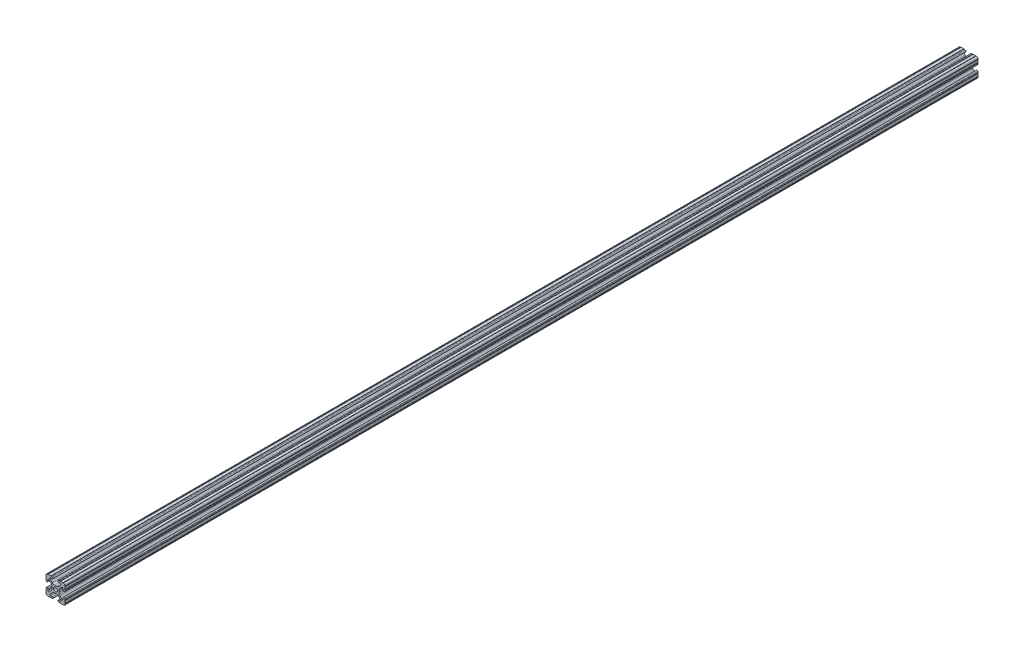
from build123d import *

# Parameters (mm, degrees)
SKETCH3_R      = 2.6035
EXTRUDE1_DEPTH = 609.6


with BuildPart() as part:
    # Sketch3 → Extrude1 (new body, symmetric)
    with BuildSketch(Plane.XY):
        with BuildLine():
            Line((-1.115277175, 4.5085), (1.115277175, 4.5085))
            ThreePointArc((1.115277175, 4.5085), (2.806584872, 4.844922018), (4.240406305, 5.80297087))
            Line((4.240406305, 5.80297087), (7.148423664, 8.710988229))
            ThreePointArc((7.148423664, 8.710988229), (7.349906316, 9.772227925), (6.436353897, 10.348636575))
            Line((6.436353897, 10.348636575), (4.381960454, 10.276895575))
            ThreePointArc((4.381960454, 10.276895575), (3.239173075, 11.342562046), (4.304839546, 12.485349424))
            Line((4.304839546, 12.485349424), (5.728246175, 12.535055879))
            ThreePointArc((5.728246175, 12.535055879), (6.054756855, 12.230579745), (6.35923299, 12.557090424))
            Line((6.35923299, 12.557090424), (9.782092278, 12.676619304))
            ThreePointArc((9.782092278, 12.676619304), (10.108602958, 12.37214317), (10.413079092, 12.69865385))
            ThreePointArc((10.413079092, 12.69865385), (12.052764565, 12.052764565), (12.69865385, 10.413079092))
            ThreePointArc((12.69865385, 10.413079092), (12.37214317, 10.108602958), (12.676619304, 9.782092278))
            Line((12.676619304, 9.782092278), (12.557090424, 6.35923299))
            ThreePointArc((12.557090424, 6.35923299), (12.230579745, 6.054756855), (12.535055879, 5.728246175))
            Line((12.535055879, 5.728246175), (12.485349424, 4.304839546))
            ThreePointArc((12.485349424, 4.304839546), (11.342562046, 3.239173075), (10.276895575, 4.381960454))
            Line((10.276895575, 4.381960454), (10.348636575, 6.436353897))
            ThreePointArc((10.348636575, 6.436353897), (9.772227925, 7.349906316), (8.710988229, 7.148423664))
            Line((8.710988229, 7.148423664), (5.80297087, 4.240406305))
            ThreePointArc((5.80297087, 4.240406305), (4.844922018, 2.806584872), (4.5085, 1.115277175))
            Line((4.5085, 1.115277175), (4.5085, -1.115277175))
            ThreePointArc((4.5085, -1.115277175), (4.844922018, -2.806584872), (5.80297087, -4.240406305))
            Line((5.80297087, -4.240406305), (8.710988229, -7.148423664))
            ThreePointArc((8.710988229, -7.148423664), (9.772227925, -7.349906316), (10.348636575, -6.436353897))
            Line((10.348636575, -6.436353897), (10.276895575, -4.381960454))
            ThreePointArc((10.276895575, -4.381960454), (11.342562046, -3.239173075), (12.485349424, -4.304839546))
            Line((12.485349424, -4.304839546), (12.535055879, -5.728246175))
            ThreePointArc((12.535055879, -5.728246175), (12.230579745, -6.054756855), (12.557090424, -6.35923299))
            Line((12.557090424, -6.35923299), (12.676619304, -9.782092278))
            ThreePointArc((12.676619304, -9.782092278), (12.37214317, -10.108602958), (12.69865385, -10.413079092))
            ThreePointArc((12.69865385, -10.413079092), (12.052764565, -12.052764565), (10.413079092, -12.69865385))
            ThreePointArc((10.413079092, -12.69865385), (10.108602958, -12.37214317), (9.782092278, -12.676619304))
            Line((9.782092278, -12.676619304), (6.35923299, -12.557090424))
            ThreePointArc((6.35923299, -12.557090424), (6.054756855, -12.230579745), (5.728246175, -12.535055879))
            Line((5.728246175, -12.535055879), (4.304839546, -12.485349424))
            ThreePointArc((4.304839546, -12.485349424), (3.239173075, -11.342562046), (4.381960454, -10.276895575))
            Line((4.381960454, -10.276895575), (6.436353897, -10.348636575))
            ThreePointArc((6.436353897, -10.348636575), (7.349906316, -9.772227925), (7.148423664, -8.710988229))
            Line((7.148423664, -8.710988229), (4.240406305, -5.80297087))
            ThreePointArc((4.240406305, -5.80297087), (2.806584872, -4.844922018), (1.115277175, -4.5085))
            Line((1.115277175, -4.5085), (-1.115277175, -4.5085))
            ThreePointArc((-1.115277175, -4.5085), (-2.806584872, -4.844922018), (-4.240406305, -5.80297087))
            Line((-4.240406305, -5.80297087), (-7.148423664, -8.710988229))
            ThreePointArc((-7.148423664, -8.710988229), (-7.349906316, -9.772227925), (-6.436353897, -10.348636575))
            Line((-6.436353897, -10.348636575), (-4.381960454, -10.276895575))
            ThreePointArc((-4.381960454, -10.276895575), (-3.239173075, -11.342562046), (-4.304839546, -12.485349424))
            Line((-4.304839546, -12.485349424), (-5.728246175, -12.535055879))
            ThreePointArc((-5.728246175, -12.535055879), (-6.054756855, -12.230579745), (-6.35923299, -12.557090424))
            Line((-6.35923299, -12.557090424), (-9.782092278, -12.676619304))
            ThreePointArc((-9.782092278, -12.676619304), (-10.108602958, -12.37214317), (-10.413079092, -12.69865385))
            ThreePointArc((-10.413079092, -12.69865385), (-12.052764565, -12.052764565), (-12.69865385, -10.413079092))
            ThreePointArc((-12.69865385, -10.413079092), (-12.37214317, -10.108602958), (-12.676619304, -9.782092278))
            Line((-12.676619304, -9.782092278), (-12.557090424, -6.35923299))
            ThreePointArc((-12.557090424, -6.35923299), (-12.230579745, -6.054756855), (-12.535055879, -5.728246175))
            Line((-12.535055879, -5.728246175), (-12.485349424, -4.304839546))
            ThreePointArc((-12.485349424, -4.304839546), (-11.342562046, -3.239173075), (-10.276895575, -4.381960454))
            Line((-10.276895575, -4.381960454), (-10.348636575, -6.436353897))
            ThreePointArc((-10.348636575, -6.436353897), (-9.772227925, -7.349906316), (-8.710988229, -7.148423664))
            Line((-8.710988229, -7.148423664), (-5.80297087, -4.240406305))
            ThreePointArc((-5.80297087, -4.240406305), (-4.844922018, -2.806584872), (-4.5085, -1.115277175))
            Line((-4.5085, -1.115277175), (-4.5085, 1.115277175))
            ThreePointArc((-4.5085, 1.115277175), (-4.844922018, 2.806584872), (-5.80297087, 4.240406305))
            Line((-5.80297087, 4.240406305), (-8.710988229, 7.148423664))
            ThreePointArc((-8.710988229, 7.148423664), (-9.772227925, 7.349906316), (-10.348636575, 6.436353897))
            Line((-10.348636575, 6.436353897), (-10.276895575, 4.381960454))
            ThreePointArc((-10.276895575, 4.381960454), (-11.342562046, 3.239173075), (-12.485349424, 4.304839546))
            Line((-12.485349424, 4.304839546), (-12.535055879, 5.728246175))
            ThreePointArc((-12.535055879, 5.728246175), (-12.230579745, 6.054756855), (-12.557090424, 6.35923299))
            Line((-12.557090424, 6.35923299), (-12.676619304, 9.782092278))
            ThreePointArc((-12.676619304, 9.782092278), (-12.37214317, 10.108602958), (-12.69865385, 10.413079092))
            ThreePointArc((-12.69865385, 10.413079092), (-12.052764565, 12.052764565), (-10.413079092, 12.69865385))
            ThreePointArc((-10.413079092, 12.69865385), (-10.108602958, 12.37214317), (-9.782092278, 12.676619304))
            Line((-9.782092278, 12.676619304), (-6.35923299, 12.557090424))
            ThreePointArc((-6.35923299, 12.557090424), (-6.054756855, 12.230579745), (-5.728246175, 12.535055879))
            Line((-5.728246175, 12.535055879), (-4.304839546, 12.485349424))
            ThreePointArc((-4.304839546, 12.485349424), (-3.239173075, 11.342562046), (-4.381960454, 10.276895575))
            Line((-4.381960454, 10.276895575), (-6.436353897, 10.348636575))
            ThreePointArc((-6.436353897, 10.348636575), (-7.349906316, 9.772227925), (-7.148423664, 8.710988229))
            Line((-7.148423664, 8.710988229), (-4.240406305, 5.80297087))
            ThreePointArc((-4.240406305, 5.80297087), (-2.806584872, 4.844922018), (-1.115277175, 4.5085))
        make_face()
        Circle(SKETCH3_R, mode=Mode.SUBTRACT)
    extrude(amount=EXTRUDE1_DEPTH, both=True)


solid = part.part
